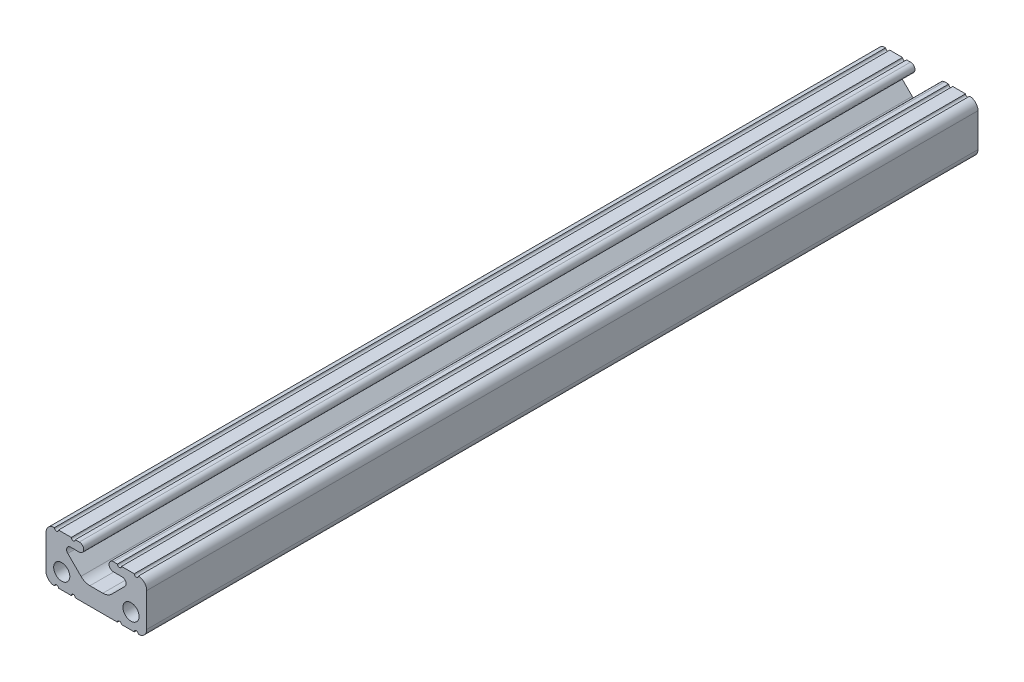
from build123d import *

# Parameters (mm, degrees)
SKETCH1_R           = 2.032
BOSS_EXTRUDE1_DEPTH = 304.8
SKETCH2_W           = 42.88308167
SKETCH2_H           = 34.457496419
CUT_EXTRUDE1_DEPTH  = 400


with BuildPart() as part:
    # Sketch1 → Boss-Extrude1 (new body, symmetric)
    with BuildSketch(Plane.XY):
        with BuildLine():
            Line((-12.7, 10.591838253), (-12.7, 2.108161747))
            ThreePointArc((-12.7, 2.108161747), (-12.078025605, 0.612955845), (-10.5791, 0))
            ThreePointArc((-10.5791, 0), (-10.06475, 0.508039196), (-9.5504, 0))
            Line((-9.5504, 0), (-6.3246, 0))
            ThreePointArc((-6.3246, 0), (-5.8166, 0.508), (-5.3086, 0))
            Line((-5.3086, 0), (5.3086, 0))
            ThreePointArc((5.3086, 0), (5.8166, 0.508), (6.3246, 0))
            Line((6.3246, 0), (9.5504, 0))
            ThreePointArc((9.5504, 0), (10.06475, 0.508039196), (10.5791, 0))
            ThreePointArc((10.5791, 0), (12.078025605, 0.612955845), (12.7, 2.108161747))
            Line((12.7, 2.108161747), (12.7, 10.591838253))
            ThreePointArc((12.7, 10.591838253), (12.078025605, 12.087044155), (10.5791, 12.7))
            ThreePointArc((10.5791, 12.7), (10.06475, 12.191960804), (9.5504, 12.7))
            Line((9.5504, 12.7), (6.3246, 12.7))
            ThreePointArc((6.3246, 12.7), (5.816599999, 12.191999983), (5.3086, 12.700000002))
            Line((5.3086, 12.700000002), (4.302307889, 12.700000002))
            ThreePointArc((4.302307889, 12.700000002), (3.197407889, 11.595100002), (4.302307889, 10.490200002))
            Line((4.302307889, 10.490200002), (6.487959021, 10.490200002))
            ThreePointArc((6.487959021, 10.490200002), (7.426620626, 9.863006369), (7.20637951, 8.755779512))
            Line((7.20637951, 8.755779512), (3.87633597, 5.425735971))
            ThreePointArc((3.87633597, 5.425735971), (2.846291837, 4.737482486), (1.631271939, 4.495800002))
            Line((1.631271939, 4.495800002), (-1.631271939, 4.495800002))
            ThreePointArc((-1.631271939, 4.495800002), (-2.846291837, 4.737482486), (-3.87633597, 5.425735971))
            Line((-3.87633597, 5.425735971), (-7.20637951, 8.755779512))
            ThreePointArc((-7.20637951, 8.755779512), (-7.426620626, 9.863006369), (-6.487959021, 10.490200002))
            Line((-6.487959021, 10.490200002), (-4.302307889, 10.490200002))
            ThreePointArc((-4.302307889, 10.490200002), (-3.197407889, 11.595100002), (-4.302307889, 12.700000002))
            Line((-4.302307889, 12.700000002), (-5.3086, 12.700000002))
            ThreePointArc((-5.3086, 12.700000002), (-5.816599999, 12.191999985), (-6.3246, 12.7))
            Line((-6.3246, 12.7), (-9.5504, 12.7))
            ThreePointArc((-9.5504, 12.7), (-10.06475, 12.191960804), (-10.5791, 12.7))
            ThreePointArc((-10.5791, 12.7), (-12.078025605, 12.087044155), (-12.7, 10.591838253))
        make_face()
        with Locations((-8.73125, 3.9624)):
            Circle(SKETCH1_R, mode=Mode.SUBTRACT)
        with Locations((8.73125, 3.9624)):
            Circle(SKETCH1_R, mode=Mode.SUBTRACT)
    extrude(amount=BOSS_EXTRUDE1_DEPTH, both=True)

    # Sketch2 → Cut-Extrude1 (cut)
    with BuildSketch(Plane(origin=(0, 0, -304.8), x_dir=(-1, 0, 0), z_dir=(0, 0, -1))):
        with Locations((2.724035754, 4.894294136)):
            Rectangle(SKETCH2_W, SKETCH2_H)
    extrude(amount=-CUT_EXTRUDE1_DEPTH, mode=Mode.SUBTRACT)


solid = part.part
